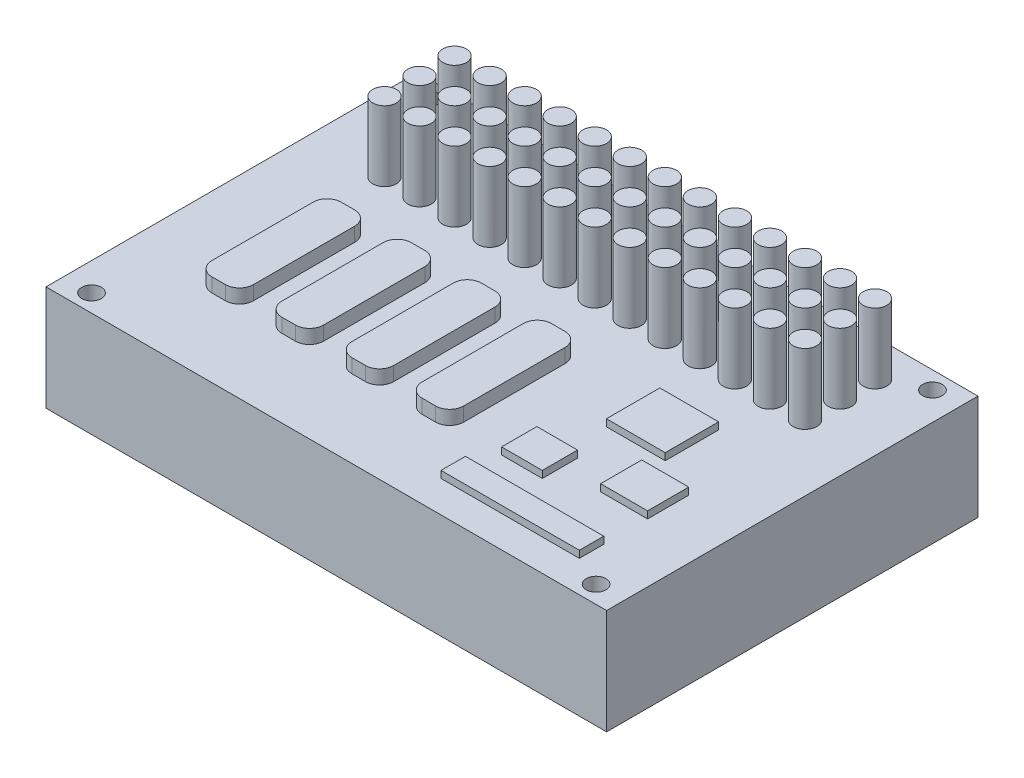
from build123d import *

# Parameters (mm, degrees)
SKETCH_1_R      = 1.4
EXTRUDE_1_DEPTH = 15
SKETCH_2_R      = 1.682017604
EXTRUDE_2_DEPTH = 10
EXTRUDE_3_DEPTH = 2
SKETCH_4_W      = 8.385315984
SKETCH_4_H      = 7.611286816
SKETCH_4_W_2    = 5.805218758
SKETCH_4_H_2    = 5.031189591
SKETCH_4_W_3    = 6.708252787
SKETCH_4_H_3    = 5.869721189
SKETCH_4_W_4    = 19.737743777
SKETCH_4_H_4    = 3.483131255
EXTRUDE_4_DEPTH = 1


with BuildPart() as part:
    # 草图1 → 凸台-拉伸1 (new body)
    with BuildSketch(Plane(origin=(0, 0, 0), x_dir=(1, 0, 0), z_dir=(0, 1, 0))):
        Polygon((80, 53), (80, 0), (0, 0), (0, 53), (39.5, 53), (41.5, 53), align=None)
        with Locations((76, 50.5)):
            Circle(SKETCH_1_R, mode=Mode.SUBTRACT)
        with Locations((76, 2.5)):
            Circle(SKETCH_1_R, mode=Mode.SUBTRACT)
        with Locations((4, 50.5)):
            Circle(SKETCH_1_R, mode=Mode.SUBTRACT)
        with Locations((4, 2.5)):
            Circle(SKETCH_1_R, mode=Mode.SUBTRACT)
    extrude(amount=EXTRUDE_1_DEPTH)

    # 草图2 → 凸台-拉伸2 (add)
    with BuildSketch(Plane(origin=(0, 15, 0), x_dir=(1, 0, 0), z_dir=(0, 1, 0))):
        with Locations((10.586891626, 47.721299682)):
            Circle(SKETCH_2_R)
        with Locations((15.586891626, 47.721299682)):
            Circle(SKETCH_2_R)
        with Locations((20.586891626, 47.721299682)):
            Circle(SKETCH_2_R)
        with Locations((25.586891626, 47.721299682)):
            Circle(SKETCH_2_R)
        with Locations((30.586891626, 47.721299682)):
            Circle(SKETCH_2_R)
        with Locations((35.586891626, 47.721299682)):
            Circle(SKETCH_2_R)
        with Locations((40.586891626, 47.721299682)):
            Circle(SKETCH_2_R)
        with Locations((45.586891626, 47.721299682)):
            Circle(SKETCH_2_R)
        with Locations((50.586891626, 47.721299682)):
            Circle(SKETCH_2_R)
        with Locations((55.586891626, 47.721299682)):
            Circle(SKETCH_2_R)
        with Locations((60.586891626, 47.721299682)):
            Circle(SKETCH_2_R)
        with Locations((65.586891626, 47.721299682)):
            Circle(SKETCH_2_R)
        with Locations((70.586891626, 47.721299682)):
            Circle(SKETCH_2_R)
        with Locations((15.586891626, 42.721299682)):
            Circle(SKETCH_2_R)
        with Locations((20.586891626, 42.721299682)):
            Circle(SKETCH_2_R)
        with Locations((25.586891626, 42.721299682)):
            Circle(SKETCH_2_R)
        with Locations((30.586891626, 42.721299682)):
            Circle(SKETCH_2_R)
        with Locations((35.586891626, 42.721299682)):
            Circle(SKETCH_2_R)
        with Locations((40.586891626, 42.721299682)):
            Circle(SKETCH_2_R)
        with Locations((45.586891626, 42.721299682)):
            Circle(SKETCH_2_R)
        with Locations((50.586891626, 42.721299682)):
            Circle(SKETCH_2_R)
        with Locations((55.586891626, 42.721299682)):
            Circle(SKETCH_2_R)
        with Locations((60.586891626, 42.721299682)):
            Circle(SKETCH_2_R)
        with Locations((65.586891626, 42.721299682)):
            Circle(SKETCH_2_R)
        with Locations((70.586891626, 42.721299682)):
            Circle(SKETCH_2_R)
        with Locations((15.586891626, 37.721299682)):
            Circle(SKETCH_2_R)
        with Locations((20.586891626, 37.721299682)):
            Circle(SKETCH_2_R)
        with Locations((25.586891626, 37.721299682)):
            Circle(SKETCH_2_R)
        with Locations((30.586891626, 37.721299682)):
            Circle(SKETCH_2_R)
        with Locations((35.586891626, 37.721299682)):
            Circle(SKETCH_2_R)
        with Locations((40.586891626, 37.721299682)):
            Circle(SKETCH_2_R)
        with Locations((45.586891626, 37.721299682)):
            Circle(SKETCH_2_R)
        with Locations((50.586891626, 37.721299682)):
            Circle(SKETCH_2_R)
        with Locations((55.586891626, 37.721299682)):
            Circle(SKETCH_2_R)
        with Locations((60.586891626, 37.721299682)):
            Circle(SKETCH_2_R)
        with Locations((65.586891626, 37.721299682)):
            Circle(SKETCH_2_R)
        with Locations((70.586891626, 37.721299682)):
            Circle(SKETCH_2_R)
        with Locations((10.586891626, 42.721299682)):
            Circle(SKETCH_2_R)
        with Locations((10.586891626, 37.721299682)):
            Circle(SKETCH_2_R)
    extrude(amount=EXTRUDE_2_DEPTH)

    # 草图3 → 凸台-拉伸3 (add)
    with BuildSketch(Plane(origin=(0, 15, 0), x_dir=(1, 0, 0), z_dir=(0, 1, 0))):
        with BuildLine():
            Line((20.586891626, 27.53161424), (20.586891626, 13.083919076))
            ThreePointArc((20.586891626, 13.083919076), (21.172678064, 11.669705513), (22.586891626, 11.083919076))
            Line((22.586891626, 11.083919076), (24.521115245, 11.083919076))
            ThreePointArc((24.521115245, 11.083919076), (25.935328808, 11.669705513), (26.521115245, 13.083919076))
            Line((26.521115245, 13.083919076), (26.521115245, 27.53161424))
            ThreePointArc((26.521115245, 27.53161424), (25.935328808, 28.945827803), (24.521115245, 29.53161424))
            Line((24.521115245, 29.53161424), (22.586891626, 29.53161424))
            ThreePointArc((22.586891626, 29.53161424), (21.172678064, 28.945827803), (20.586891626, 27.53161424))
        make_face()
        with BuildLine():
            Line((12.586891626, 29.53161424), (14.521115245, 29.53161424))
            ThreePointArc((14.521115245, 29.53161424), (15.935328808, 28.945827803), (16.521115245, 27.53161424))
            Line((16.521115245, 27.53161424), (16.521115245, 13.083919076))
            ThreePointArc((16.521115245, 13.083919076), (15.935328808, 11.669705513), (14.521115245, 11.083919076))
            Line((14.521115245, 11.083919076), (12.586891626, 11.083919076))
            ThreePointArc((12.586891626, 11.083919076), (11.172678064, 11.669705513), (10.586891626, 13.083919076))
            Line((10.586891626, 13.083919076), (10.586891626, 27.53161424))
            ThreePointArc((10.586891626, 27.53161424), (11.172678064, 28.945827803), (12.586891626, 29.53161424))
        make_face()
        with BuildLine():
            Line((30.586891626, 27.53161424), (30.586891626, 13.083919076))
            ThreePointArc((30.586891626, 13.083919076), (31.172678064, 11.669705513), (32.586891626, 11.083919076))
            Line((32.586891626, 11.083919076), (34.521115245, 11.083919076))
            ThreePointArc((34.521115245, 11.083919076), (35.935328808, 11.669705513), (36.521115245, 13.083919076))
            Line((36.521115245, 13.083919076), (36.521115245, 27.53161424))
            ThreePointArc((36.521115245, 27.53161424), (35.935328808, 28.945827803), (34.521115245, 29.53161424))
            Line((34.521115245, 29.53161424), (32.586891626, 29.53161424))
            ThreePointArc((32.586891626, 29.53161424), (31.172678064, 28.945827803), (30.586891626, 27.53161424))
        make_face()
        with BuildLine():
            Line((40.586891626, 27.53161424), (40.586891626, 13.083919076))
            ThreePointArc((40.586891626, 13.083919076), (41.172678064, 11.669705513), (42.586891626, 11.083919076))
            Line((42.586891626, 11.083919076), (44.521115245, 11.083919076))
            ThreePointArc((44.521115245, 11.083919076), (45.935328808, 11.669705513), (46.521115245, 13.083919076))
            Line((46.521115245, 13.083919076), (46.521115245, 27.53161424))
            ThreePointArc((46.521115245, 27.53161424), (45.935328808, 28.945827803), (44.521115245, 29.53161424))
            Line((44.521115245, 29.53161424), (42.586891626, 29.53161424))
            ThreePointArc((42.586891626, 29.53161424), (41.172678064, 28.945827803), (40.586891626, 27.53161424))
        make_face()
    extrude(amount=EXTRUDE_3_DEPTH)

    # 草图4 → 凸台-拉伸4 (add)
    with BuildSketch(Plane(origin=(0, 15, 0), x_dir=(1, 0, 0), z_dir=(0, 1, 0))):
        with Locations((61.479309405, 26.5)):
            Rectangle(SKETCH_4_W, SKETCH_4_H)
        with Locations((56.190110092, 14.244538178)):
            Rectangle(SKETCH_4_W_2, SKETCH_4_H_2)
        with Locations((68.252064623, 17.179398772)):
            Rectangle(SKETCH_4_W_3, SKETCH_4_H_3)
        with Locations((61.737319128, 6.246236778)):
            Rectangle(SKETCH_4_W_4, SKETCH_4_H_4)
    extrude(amount=EXTRUDE_4_DEPTH)


solid = part.part
